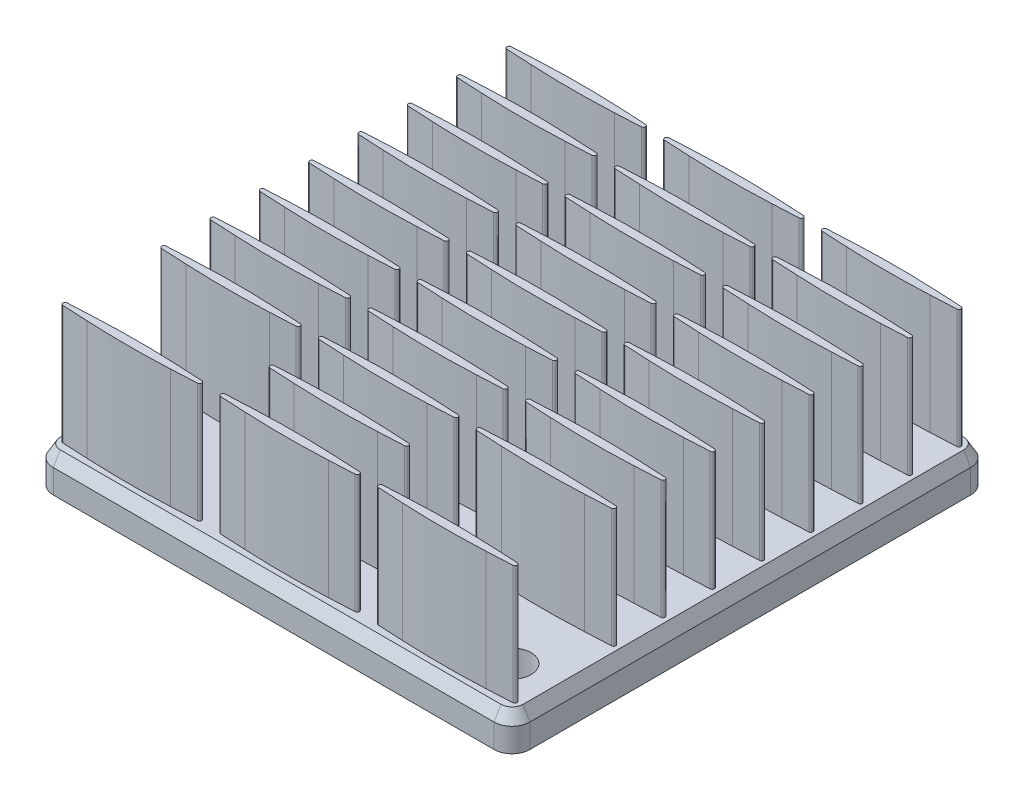
from build123d import *

# Parameters (mm, degrees)
BOSS_EXTRUDE1_DEPTH  = 1
BOSS_EXTRUDE1_TAPER  = -30
BOSS_EXTRUDE2_DEPTH  = 2
BOSS_EXTRUDE3_DEPTH  = 10
BOSS_EXTRUDE4_DEPTH  = 12
BOSS_EXTRUDE5_DEPTH  = 12
BOSS_EXTRUDE6_DEPTH  = 12
BOSS_EXTRUDE7_DEPTH  = 12
BOSS_EXTRUDE8_DEPTH  = 12
BOSS_EXTRUDE9_DEPTH  = 12
BOSS_EXTRUDE10_DEPTH = 12
BOSS_EXTRUDE11_DEPTH = 12
BOSS_EXTRUDE12_DEPTH = 12
BOSS_EXTRUDE13_DEPTH = 12
BOSS_EXTRUDE14_DEPTH = 12
BOSS_EXTRUDE15_DEPTH = 12
BOSS_EXTRUDE16_DEPTH = 12
BOSS_EXTRUDE17_DEPTH = 12
BOSS_EXTRUDE18_DEPTH = 12
BOSS_EXTRUDE19_DEPTH = 12
BOSS_EXTRUDE20_DEPTH = 12
BOSS_EXTRUDE21_DEPTH = 12
BOSS_EXTRUDE22_DEPTH = 12
BOSS_EXTRUDE23_DEPTH = 12
BOSS_EXTRUDE24_DEPTH = 12
BOSS_EXTRUDE25_DEPTH = 12
BOSS_EXTRUDE26_DEPTH = 12
BOSS_EXTRUDE28_DEPTH = 12
BOSS_EXTRUDE30_DEPTH = 12
BOSS_EXTRUDE31_DEPTH = 12
BOSS_EXTRUDE32_DEPTH = 12
SKETCH34_W           = 57.280047681
SKETCH34_H           = 53.627576078
CUT_EXTRUDE1_DEPTH   = 2
SKETCH35_R           = 1.6
CUT_EXTRUDE2_DEPTH   = 10


with BuildPart() as part:
    # Sketch1 → Boss-Extrude1 (new body)
    with BuildSketch(Plane(origin=(0, 3, 0), x_dir=(1, 0, 0), z_dir=(0, 1, 0))):
        with BuildLine():
            Line((-19.422649731, 18.5), (-19.422649731, -18.5))
            ThreePointArc((-19.422649731, -18.5), (-19.152411881, -19.152411881), (-18.5, -19.422649731))
            Line((-18.5, -19.422649731), (18.5, -19.422649731))
            ThreePointArc((18.5, -19.422649731), (19.152411881, -19.152411881), (19.422649731, -18.5))
            Line((19.422649731, -18.5), (19.422649731, 18.5))
            ThreePointArc((19.422649731, 18.5), (19.152411881, 19.152411881), (18.5, 19.422649731))
            Line((18.5, 19.422649731), (-18.5, 19.422649731))
            ThreePointArc((-18.5, 19.422649731), (-19.152411881, 19.152411881), (-19.422649731, 18.5))
        make_face()
    extrude(amount=-BOSS_EXTRUDE1_DEPTH, taper=BOSS_EXTRUDE1_TAPER)

    # Sketch2 → Boss-Extrude2 (add)
    with BuildSketch(Plane.XZ.offset(-2)):
        with BuildLine():
            Line((-20, -18.5), (-20, 18.5))
            ThreePointArc((-20, 18.5), (-19.560660172, 19.560660172), (-18.5, 20))
            Line((-18.5, 20), (18.5, 20))
            ThreePointArc((18.5, 20), (19.560660172, 19.560660172), (20, 18.5))
            Line((20, 18.5), (20, -18.5))
            ThreePointArc((20, -18.5), (19.560660172, -19.560660172), (18.5, -20))
            Line((18.5, -20), (-18.5, -20))
            ThreePointArc((-18.5, -20), (-19.560660172, -19.560660172), (-20, -18.5))
        make_face()
    extrude(amount=BOSS_EXTRUDE2_DEPTH)

    # Sketch3 → Boss-Extrude3 (add)
    with BuildSketch(Plane(origin=(0, 3, 0), x_dir=(-1, 0, 0), z_dir=(0, 1, 0))):
        with BuildLine():
            Line((-16.742786756, -18.917305676), (-18.889007166, -18.8097745))
            ThreePointArc((-18.889007166, -18.8097745), (-19.06, -18.63), (-18.889007166, -18.4502255))
            Line((-18.889007166, -18.4502255), (-16.742786756, -18.342694324))
            ThreePointArc((-16.742786756, -18.342694324), (-13.24, -18.255), (-9.737213244, -18.342694324))
            Line((-9.737213244, -18.342694324), (-7.590992834, -18.4502255))
            ThreePointArc((-7.590992834, -18.4502255), (-7.42, -18.63), (-7.590992834, -18.8097745))
            Line((-7.590992834, -18.8097745), (-9.737213244, -18.917305676))
            ThreePointArc((-9.737213244, -18.917305676), (-13.24, -19.005), (-16.742786756, -18.917305676))
        make_face()
    extrude(amount=BOSS_EXTRUDE3_DEPTH)

    # Sketch4 → Boss-Extrude4 (add)
    with BuildSketch(Plane(origin=(0, 3, 0), x_dir=(-1, 0, 0), z_dir=(0, 1, 0))):
        with BuildLine():
            Line((-3.502786756, -18.917305676), (-5.649007166, -18.8097745))
            ThreePointArc((-5.649007166, -18.8097745), (-5.82, -18.63), (-5.649007166, -18.4502255))
            Line((-5.649007166, -18.4502255), (-3.502786756, -18.342694324))
            ThreePointArc((-3.502786756, -18.342694324), (0, -18.255), (3.502786756, -18.342694324))
            Line((3.502786756, -18.342694324), (5.649007166, -18.4502255))
            ThreePointArc((5.649007166, -18.4502255), (5.82, -18.63), (5.649007166, -18.8097745))
            Line((5.649007166, -18.8097745), (3.502786756, -18.917305676))
            ThreePointArc((3.502786756, -18.917305676), (0, -19.005), (-3.502786756, -18.917305676))
        make_face()
    extrude(amount=BOSS_EXTRUDE4_DEPTH)

    # Sketch5 → Boss-Extrude5 (add)
    with BuildSketch(Plane(origin=(0, 3, 0), x_dir=(-1, 0, 0), z_dir=(0, 1, 0))):
        with BuildLine():
            Line((9.737213244, -18.917305676), (7.590992834, -18.8097745))
            ThreePointArc((7.590992834, -18.8097745), (7.42, -18.63), (7.590992834, -18.4502255))
            Line((7.590992834, -18.4502255), (9.737213244, -18.342694324))
            ThreePointArc((9.737213244, -18.342694324), (13.24, -18.255), (16.742786756, -18.342694324))
            Line((16.742786756, -18.342694324), (18.889007166, -18.4502255))
            ThreePointArc((18.889007166, -18.4502255), (19.06, -18.63), (18.889007166, -18.8097745))
            Line((18.889007166, -18.8097745), (16.742786756, -18.917305676))
            ThreePointArc((16.742786756, -18.917305676), (13.24, -19.005), (9.737213244, -18.917305676))
        make_face()
    extrude(amount=BOSS_EXTRUDE5_DEPTH)

    # Sketch6 → Boss-Extrude6 (add)
    with BuildSketch(Plane(origin=(0, 3, 0), x_dir=(-1, 0, 0), z_dir=(0, 1, 0))):
        with BuildLine():
            Line((-16.742786756, -14.777305676), (-18.889007166, -14.6697745))
            ThreePointArc((-18.889007166, -14.6697745), (-19.06, -14.49), (-18.889007166, -14.3102255))
            Line((-18.889007166, -14.3102255), (-16.742786756, -14.202694324))
            ThreePointArc((-16.742786756, -14.202694324), (-13.24, -14.115), (-9.737213244, -14.202694324))
            Line((-9.737213244, -14.202694324), (-7.590992834, -14.3102255))
            ThreePointArc((-7.590992834, -14.3102255), (-7.42, -14.49), (-7.590992834, -14.6697745))
            Line((-7.590992834, -14.6697745), (-9.737213244, -14.777305676))
            ThreePointArc((-9.737213244, -14.777305676), (-13.24, -14.865), (-16.742786756, -14.777305676))
        make_face()
    extrude(amount=BOSS_EXTRUDE6_DEPTH)

    # Sketch7 → Boss-Extrude7 (add)
    with BuildSketch(Plane(origin=(0, 3, 0), x_dir=(-1, 0, 0), z_dir=(0, 1, 0))):
        with BuildLine():
            Line((-3.502786756, -14.777305676), (-5.649007166, -14.6697745))
            ThreePointArc((-5.649007166, -14.6697745), (-5.82, -14.49), (-5.649007166, -14.3102255))
            Line((-5.649007166, -14.3102255), (-3.502786756, -14.202694324))
            ThreePointArc((-3.502786756, -14.202694324), (0, -14.115), (3.502786756, -14.202694324))
            Line((3.502786756, -14.202694324), (5.649007166, -14.3102255))
            ThreePointArc((5.649007166, -14.3102255), (5.82, -14.49), (5.649007166, -14.6697745))
            Line((5.649007166, -14.6697745), (3.502786756, -14.777305676))
            ThreePointArc((3.502786756, -14.777305676), (0, -14.865), (-3.502786756, -14.777305676))
        make_face()
    extrude(amount=BOSS_EXTRUDE7_DEPTH)

    # Sketch8 → Boss-Extrude8 (add)
    with BuildSketch(Plane(origin=(0, 3, 0), x_dir=(-1, 0, 0), z_dir=(0, 1, 0))):
        with BuildLine():
            Line((9.737213244, -14.777305676), (7.590992834, -14.6697745))
            ThreePointArc((7.590992834, -14.6697745), (7.42, -14.49), (7.590992834, -14.3102255))
            Line((7.590992834, -14.3102255), (9.737213244, -14.202694324))
            ThreePointArc((9.737213244, -14.202694324), (13.24, -14.115), (16.742786756, -14.202694324))
            Line((16.742786756, -14.202694324), (18.889007166, -14.3102255))
            ThreePointArc((18.889007166, -14.3102255), (19.06, -14.49), (18.889007166, -14.6697745))
            Line((18.889007166, -14.6697745), (16.742786756, -14.777305676))
            ThreePointArc((16.742786756, -14.777305676), (13.24, -14.865), (9.737213244, -14.777305676))
        make_face()
    extrude(amount=BOSS_EXTRUDE8_DEPTH)

    # Sketch9 → Boss-Extrude9 (add)
    with BuildSketch(Plane(origin=(0, 3, 0), x_dir=(-1, 0, 0), z_dir=(0, 1, 0))):
        with BuildLine():
            Line((-16.742786756, -10.637305676), (-18.889007166, -10.5297745))
            ThreePointArc((-18.889007166, -10.5297745), (-19.06, -10.35), (-18.889007166, -10.1702255))
            Line((-18.889007166, -10.1702255), (-16.742786756, -10.062694324))
            ThreePointArc((-16.742786756, -10.062694324), (-13.24, -9.975), (-9.737213244, -10.062694324))
            Line((-9.737213244, -10.062694324), (-7.590992834, -10.1702255))
            ThreePointArc((-7.590992834, -10.1702255), (-7.42, -10.35), (-7.590992834, -10.5297745))
            Line((-7.590992834, -10.5297745), (-9.737213244, -10.637305676))
            ThreePointArc((-9.737213244, -10.637305676), (-13.24, -10.725), (-16.742786756, -10.637305676))
        make_face()
    extrude(amount=BOSS_EXTRUDE9_DEPTH)

    # Sketch10 → Boss-Extrude10 (add)
    with BuildSketch(Plane(origin=(0, 3, 0), x_dir=(-1, 0, 0), z_dir=(0, 1, 0))):
        with BuildLine():
            Line((-3.502786756, -10.637305676), (-5.649007166, -10.5297745))
            ThreePointArc((-5.649007166, -10.5297745), (-5.82, -10.35), (-5.649007166, -10.1702255))
            Line((-5.649007166, -10.1702255), (-3.502786756, -10.062694324))
            ThreePointArc((-3.502786756, -10.062694324), (0, -9.975), (3.502786756, -10.062694324))
            Line((3.502786756, -10.062694324), (5.649007166, -10.1702255))
            ThreePointArc((5.649007166, -10.1702255), (5.82, -10.35), (5.649007166, -10.5297745))
            Line((5.649007166, -10.5297745), (3.502786756, -10.637305676))
            ThreePointArc((3.502786756, -10.637305676), (0, -10.725), (-3.502786756, -10.637305676))
        make_face()
    extrude(amount=BOSS_EXTRUDE10_DEPTH)

    # Sketch11 → Boss-Extrude11 (add)
    with BuildSketch(Plane(origin=(0, 3, 0), x_dir=(-1, 0, 0), z_dir=(0, 1, 0))):
        with BuildLine():
            Line((9.737213244, -10.637305676), (7.590992834, -10.5297745))
            ThreePointArc((7.590992834, -10.5297745), (7.42, -10.35), (7.590992834, -10.1702255))
            Line((7.590992834, -10.1702255), (9.737213244, -10.062694324))
            ThreePointArc((9.737213244, -10.062694324), (13.24, -9.975), (16.742786756, -10.062694324))
            Line((16.742786756, -10.062694324), (18.889007166, -10.1702255))
            ThreePointArc((18.889007166, -10.1702255), (19.06, -10.35), (18.889007166, -10.5297745))
            Line((18.889007166, -10.5297745), (16.742786756, -10.637305676))
            ThreePointArc((16.742786756, -10.637305676), (13.24, -10.725), (9.737213244, -10.637305676))
        make_face()
    extrude(amount=BOSS_EXTRUDE11_DEPTH)

    # Sketch12 → Boss-Extrude12 (add)
    with BuildSketch(Plane(origin=(0, 3, 0), x_dir=(-1, 0, 0), z_dir=(0, 1, 0))):
        with BuildLine():
            Line((-16.742786756, -6.497305676), (-18.889007166, -6.3897745))
            ThreePointArc((-18.889007166, -6.3897745), (-19.06, -6.21), (-18.889007166, -6.0302255))
            Line((-18.889007166, -6.0302255), (-16.742786756, -5.922694324))
            ThreePointArc((-16.742786756, -5.922694324), (-13.24, -5.835), (-9.737213244, -5.922694324))
            Line((-9.737213244, -5.922694324), (-7.590992834, -6.0302255))
            ThreePointArc((-7.590992834, -6.0302255), (-7.42, -6.21), (-7.590992834, -6.3897745))
            Line((-7.590992834, -6.3897745), (-9.737213244, -6.497305676))
            ThreePointArc((-9.737213244, -6.497305676), (-13.24, -6.585), (-16.742786756, -6.497305676))
        make_face()
    extrude(amount=BOSS_EXTRUDE12_DEPTH)

    # Sketch13 → Boss-Extrude13 (add)
    with BuildSketch(Plane(origin=(0, 3, 0), x_dir=(-1, 0, 0), z_dir=(0, 1, 0))):
        with BuildLine():
            Line((-3.502786756, -6.497305676), (-5.649007166, -6.3897745))
            ThreePointArc((-5.649007166, -6.3897745), (-5.82, -6.21), (-5.649007166, -6.0302255))
            Line((-5.649007166, -6.0302255), (-3.502786756, -5.922694324))
            ThreePointArc((-3.502786756, -5.922694324), (0, -5.835), (3.502786756, -5.922694324))
            Line((3.502786756, -5.922694324), (5.649007166, -6.0302255))
            ThreePointArc((5.649007166, -6.0302255), (5.82, -6.21), (5.649007166, -6.3897745))
            Line((5.649007166, -6.3897745), (3.502786756, -6.497305676))
            ThreePointArc((3.502786756, -6.497305676), (0, -6.585), (-3.502786756, -6.497305676))
        make_face()
    extrude(amount=BOSS_EXTRUDE13_DEPTH)

    # Sketch14 → Boss-Extrude14 (add)
    with BuildSketch(Plane(origin=(0, 3, 0), x_dir=(-1, 0, 0), z_dir=(0, 1, 0))):
        with BuildLine():
            Line((9.737213244, -6.497305676), (7.590992834, -6.3897745))
            ThreePointArc((7.590992834, -6.3897745), (7.42, -6.21), (7.590992834, -6.0302255))
            Line((7.590992834, -6.0302255), (9.737213244, -5.922694324))
            ThreePointArc((9.737213244, -5.922694324), (13.24, -5.835), (16.742786756, -5.922694324))
            Line((16.742786756, -5.922694324), (18.889007166, -6.0302255))
            ThreePointArc((18.889007166, -6.0302255), (19.06, -6.21), (18.889007166, -6.3897745))
            Line((18.889007166, -6.3897745), (16.742786756, -6.497305676))
            ThreePointArc((16.742786756, -6.497305676), (13.24, -6.585), (9.737213244, -6.497305676))
        make_face()
    extrude(amount=BOSS_EXTRUDE14_DEPTH)

    # Sketch15 → Boss-Extrude15 (add)
    with BuildSketch(Plane(origin=(0, 3, 0), x_dir=(-1, 0, 0), z_dir=(0, 1, 0))):
        with BuildLine():
            Line((-16.742786756, -2.357305676), (-18.889007166, -2.2497745))
            ThreePointArc((-18.889007166, -2.2497745), (-19.06, -2.07), (-18.889007166, -1.8902255))
            Line((-18.889007166, -1.8902255), (-16.742786756, -1.782694324))
            ThreePointArc((-16.742786756, -1.782694324), (-13.24, -1.695), (-9.737213244, -1.782694324))
            Line((-9.737213244, -1.782694324), (-7.590992834, -1.8902255))
            ThreePointArc((-7.590992834, -1.8902255), (-7.42, -2.07), (-7.590992834, -2.2497745))
            Line((-7.590992834, -2.2497745), (-9.737213244, -2.357305676))
            ThreePointArc((-9.737213244, -2.357305676), (-13.24, -2.445), (-16.742786756, -2.357305676))
        make_face()
    extrude(amount=BOSS_EXTRUDE15_DEPTH)

    # Sketch16 → Boss-Extrude16 (add)
    with BuildSketch(Plane(origin=(0, 3, 0), x_dir=(-1, 0, 0), z_dir=(0, 1, 0))):
        with BuildLine():
            Line((-3.502786756, -2.357305676), (-5.649007166, -2.2497745))
            ThreePointArc((-5.649007166, -2.2497745), (-5.82, -2.07), (-5.649007166, -1.8902255))
            Line((-5.649007166, -1.8902255), (-3.502786756, -1.782694324))
            ThreePointArc((-3.502786756, -1.782694324), (0, -1.695), (3.502786756, -1.782694324))
            Line((3.502786756, -1.782694324), (5.649007166, -1.8902255))
            ThreePointArc((5.649007166, -1.8902255), (5.82, -2.07), (5.649007166, -2.2497745))
            Line((5.649007166, -2.2497745), (3.502786756, -2.357305676))
            ThreePointArc((3.502786756, -2.357305676), (0, -2.445), (-3.502786756, -2.357305676))
        make_face()
    extrude(amount=BOSS_EXTRUDE16_DEPTH)

    # Sketch17 → Boss-Extrude17 (add)
    with BuildSketch(Plane(origin=(0, 3, 0), x_dir=(-1, 0, 0), z_dir=(0, 1, 0))):
        with BuildLine():
            Line((9.737213244, -2.357305676), (7.590992834, -2.2497745))
            ThreePointArc((7.590992834, -2.2497745), (7.42, -2.07), (7.590992834, -1.8902255))
            Line((7.590992834, -1.8902255), (9.737213244, -1.782694324))
            ThreePointArc((9.737213244, -1.782694324), (13.24, -1.695), (16.742786756, -1.782694324))
            Line((16.742786756, -1.782694324), (18.889007166, -1.8902255))
            ThreePointArc((18.889007166, -1.8902255), (19.06, -2.07), (18.889007166, -2.2497745))
            Line((18.889007166, -2.2497745), (16.742786756, -2.357305676))
            ThreePointArc((16.742786756, -2.357305676), (13.24, -2.445), (9.737213244, -2.357305676))
        make_face()
    extrude(amount=BOSS_EXTRUDE17_DEPTH)

    # Sketch18 → Boss-Extrude18 (add)
    with BuildSketch(Plane(origin=(0, 3, 0), x_dir=(-1, 0, 0), z_dir=(0, 1, 0))):
        with BuildLine():
            Line((-16.742786756, 1.782694324), (-18.889007166, 1.8902255))
            ThreePointArc((-18.889007166, 1.8902255), (-19.06, 2.07), (-18.889007166, 2.2497745))
            Line((-18.889007166, 2.2497745), (-16.742786756, 2.357305676))
            ThreePointArc((-16.742786756, 2.357305676), (-13.24, 2.445), (-9.737213244, 2.357305676))
            Line((-9.737213244, 2.357305676), (-7.590992834, 2.2497745))
            ThreePointArc((-7.590992834, 2.2497745), (-7.42, 2.07), (-7.590992834, 1.8902255))
            Line((-7.590992834, 1.8902255), (-9.737213244, 1.782694324))
            ThreePointArc((-9.737213244, 1.782694324), (-13.24, 1.695), (-16.742786756, 1.782694324))
        make_face()
    extrude(amount=BOSS_EXTRUDE18_DEPTH)

    # Sketch19 → Boss-Extrude19 (add)
    with BuildSketch(Plane(origin=(0, 3, 0), x_dir=(-1, 0, 0), z_dir=(0, 1, 0))):
        with BuildLine():
            Line((-3.502786756, 1.782694324), (-5.649007166, 1.8902255))
            ThreePointArc((-5.649007166, 1.8902255), (-5.82, 2.07), (-5.649007166, 2.2497745))
            Line((-5.649007166, 2.2497745), (-3.502786756, 2.357305676))
            ThreePointArc((-3.502786756, 2.357305676), (0, 2.445), (3.502786756, 2.357305676))
            Line((3.502786756, 2.357305676), (5.649007166, 2.2497745))
            ThreePointArc((5.649007166, 2.2497745), (5.82, 2.07), (5.649007166, 1.8902255))
            Line((5.649007166, 1.8902255), (3.502786756, 1.782694324))
            ThreePointArc((3.502786756, 1.782694324), (0, 1.695), (-3.502786756, 1.782694324))
        make_face()
    extrude(amount=BOSS_EXTRUDE19_DEPTH)

    # Sketch20 → Boss-Extrude20 (add)
    with BuildSketch(Plane(origin=(0, 3, 0), x_dir=(-1, 0, 0), z_dir=(0, 1, 0))):
        with BuildLine():
            Line((9.737213244, 1.782694324), (7.590992834, 1.8902255))
            ThreePointArc((7.590992834, 1.8902255), (7.42, 2.07), (7.590992834, 2.2497745))
            Line((7.590992834, 2.2497745), (9.737213244, 2.357305676))
            ThreePointArc((9.737213244, 2.357305676), (13.24, 2.445), (16.742786756, 2.357305676))
            Line((16.742786756, 2.357305676), (18.889007166, 2.2497745))
            ThreePointArc((18.889007166, 2.2497745), (19.06, 2.07), (18.889007166, 1.8902255))
            Line((18.889007166, 1.8902255), (16.742786756, 1.782694324))
            ThreePointArc((16.742786756, 1.782694324), (13.24, 1.695), (9.737213244, 1.782694324))
        make_face()
    extrude(amount=BOSS_EXTRUDE20_DEPTH)

    # Sketch21 → Boss-Extrude21 (add)
    with BuildSketch(Plane(origin=(0, 3, 0), x_dir=(-1, 0, 0), z_dir=(0, 1, 0))):
        with BuildLine():
            Line((-16.742786756, 5.922694324), (-18.889007166, 6.0302255))
            ThreePointArc((-18.889007166, 6.0302255), (-19.06, 6.21), (-18.889007166, 6.3897745))
            Line((-18.889007166, 6.3897745), (-16.742786756, 6.497305676))
            ThreePointArc((-16.742786756, 6.497305676), (-13.24, 6.585), (-9.737213244, 6.497305676))
            Line((-9.737213244, 6.497305676), (-7.590992834, 6.3897745))
            ThreePointArc((-7.590992834, 6.3897745), (-7.42, 6.21), (-7.590992834, 6.0302255))
            Line((-7.590992834, 6.0302255), (-9.737213244, 5.922694324))
            ThreePointArc((-9.737213244, 5.922694324), (-13.24, 5.835), (-16.742786756, 5.922694324))
        make_face()
    extrude(amount=BOSS_EXTRUDE21_DEPTH)

    # Sketch22 → Boss-Extrude22 (add)
    with BuildSketch(Plane(origin=(0, 3, 0), x_dir=(-1, 0, 0), z_dir=(0, 1, 0))):
        with BuildLine():
            Line((-3.502786756, 5.922694324), (-5.649007166, 6.0302255))
            ThreePointArc((-5.649007166, 6.0302255), (-5.82, 6.21), (-5.649007166, 6.3897745))
            Line((-5.649007166, 6.3897745), (-3.502786756, 6.497305676))
            ThreePointArc((-3.502786756, 6.497305676), (0, 6.585), (3.502786756, 6.497305676))
            Line((3.502786756, 6.497305676), (5.649007166, 6.3897745))
            ThreePointArc((5.649007166, 6.3897745), (5.82, 6.21), (5.649007166, 6.0302255))
            Line((5.649007166, 6.0302255), (3.502786756, 5.922694324))
            ThreePointArc((3.502786756, 5.922694324), (0, 5.835), (-3.502786756, 5.922694324))
        make_face()
    extrude(amount=BOSS_EXTRUDE22_DEPTH)

    # Sketch23 → Boss-Extrude23 (add)
    with BuildSketch(Plane(origin=(0, 3, 0), x_dir=(-1, 0, 0), z_dir=(0, 1, 0))):
        with BuildLine():
            Line((9.737213244, 5.922694324), (7.590992834, 6.0302255))
            ThreePointArc((7.590992834, 6.0302255), (7.42, 6.21), (7.590992834, 6.3897745))
            Line((7.590992834, 6.3897745), (9.737213244, 6.497305676))
            ThreePointArc((9.737213244, 6.497305676), (13.24, 6.585), (16.742786756, 6.497305676))
            Line((16.742786756, 6.497305676), (18.889007166, 6.3897745))
            ThreePointArc((18.889007166, 6.3897745), (19.06, 6.21), (18.889007166, 6.0302255))
            Line((18.889007166, 6.0302255), (16.742786756, 5.922694324))
            ThreePointArc((16.742786756, 5.922694324), (13.24, 5.835), (9.737213244, 5.922694324))
        make_face()
    extrude(amount=BOSS_EXTRUDE23_DEPTH)

    # Sketch24 → Boss-Extrude24 (add)
    with BuildSketch(Plane(origin=(0, 3, 0), x_dir=(-1, 0, 0), z_dir=(0, 1, 0))):
        with BuildLine():
            Line((-16.742786756, 10.062694324), (-18.889007166, 10.1702255))
            ThreePointArc((-18.889007166, 10.1702255), (-19.06, 10.35), (-18.889007166, 10.5297745))
            Line((-18.889007166, 10.5297745), (-16.742786756, 10.637305676))
            ThreePointArc((-16.742786756, 10.637305676), (-13.24, 10.725), (-9.737213244, 10.637305676))
            Line((-9.737213244, 10.637305676), (-7.590992834, 10.5297745))
            ThreePointArc((-7.590992834, 10.5297745), (-7.42, 10.35), (-7.590992834, 10.1702255))
            Line((-7.590992834, 10.1702255), (-9.737213244, 10.062694324))
            ThreePointArc((-9.737213244, 10.062694324), (-13.24, 9.975), (-16.742786756, 10.062694324))
        make_face()
    extrude(amount=BOSS_EXTRUDE24_DEPTH)

    # Sketch25 → Boss-Extrude25 (add)
    with BuildSketch(Plane(origin=(0, 3, 0), x_dir=(-1, 0, 0), z_dir=(0, 1, 0))):
        with BuildLine():
            Line((-3.502786756, 10.062694324), (-5.649007166, 10.1702255))
            ThreePointArc((-5.649007166, 10.1702255), (-5.82, 10.35), (-5.649007166, 10.5297745))
            Line((-5.649007166, 10.5297745), (-3.502786756, 10.637305676))
            ThreePointArc((-3.502786756, 10.637305676), (0, 10.725), (3.502786756, 10.637305676))
            Line((3.502786756, 10.637305676), (5.649007166, 10.5297745))
            ThreePointArc((5.649007166, 10.5297745), (5.82, 10.35), (5.649007166, 10.1702255))
            Line((5.649007166, 10.1702255), (3.502786756, 10.062694324))
            ThreePointArc((3.502786756, 10.062694324), (0, 9.975), (-3.502786756, 10.062694324))
        make_face()
    extrude(amount=BOSS_EXTRUDE25_DEPTH)

    # Sketch26 → Boss-Extrude26 (add)
    with BuildSketch(Plane(origin=(0, 3, 0), x_dir=(-1, 0, 0), z_dir=(0, 1, 0))):
        with BuildLine():
            Line((9.737213244, 10.062694324), (7.590992834, 10.1702255))
            ThreePointArc((7.590992834, 10.1702255), (7.42, 10.35), (7.590992834, 10.5297745))
            Line((7.590992834, 10.5297745), (9.737213244, 10.637305676))
            ThreePointArc((9.737213244, 10.637305676), (13.24, 10.725), (16.742786756, 10.637305676))
            Line((16.742786756, 10.637305676), (18.889007166, 10.5297745))
            ThreePointArc((18.889007166, 10.5297745), (19.06, 10.35), (18.889007166, 10.1702255))
            Line((18.889007166, 10.1702255), (16.742786756, 10.062694324))
            ThreePointArc((16.742786756, 10.062694324), (13.24, 9.975), (9.737213244, 10.062694324))
        make_face()
    extrude(amount=BOSS_EXTRUDE26_DEPTH)

    # Sketch28 → Boss-Extrude28 (add)
    with BuildSketch(Plane(origin=(0, 3, 0), x_dir=(-1, 0, 0), z_dir=(0, 1, 0))):
        with BuildLine():
            Line((-3.502786756, 14.202694324), (-5.649007166, 14.3102255))
            ThreePointArc((-5.649007166, 14.3102255), (-5.82, 14.49), (-5.649007166, 14.6697745))
            Line((-5.649007166, 14.6697745), (-3.502786756, 14.777305676))
            ThreePointArc((-3.502786756, 14.777305676), (0, 14.865), (3.502786756, 14.777305676))
            Line((3.502786756, 14.777305676), (5.649007166, 14.6697745))
            ThreePointArc((5.649007166, 14.6697745), (5.82, 14.49), (5.649007166, 14.3102255))
            Line((5.649007166, 14.3102255), (3.502786756, 14.202694324))
            ThreePointArc((3.502786756, 14.202694324), (0, 14.115), (-3.502786756, 14.202694324))
        make_face()
    extrude(amount=BOSS_EXTRUDE28_DEPTH)

    # Sketch30 → Boss-Extrude30 (add)
    with BuildSketch(Plane(origin=(0, 3, 0), x_dir=(-1, 0, 0), z_dir=(0, 1, 0))):
        with BuildLine():
            Line((-16.742786756, 18.342694324), (-18.889007166, 18.4502255))
            ThreePointArc((-18.889007166, 18.4502255), (-19.06, 18.63), (-18.889007166, 18.8097745))
            Line((-18.889007166, 18.8097745), (-16.742786756, 18.917305676))
            ThreePointArc((-16.742786756, 18.917305676), (-13.24, 19.005), (-9.737213244, 18.917305676))
            Line((-9.737213244, 18.917305676), (-7.590992834, 18.8097745))
            ThreePointArc((-7.590992834, 18.8097745), (-7.42, 18.63), (-7.590992834, 18.4502255))
            Line((-7.590992834, 18.4502255), (-9.737213244, 18.342694324))
            ThreePointArc((-9.737213244, 18.342694324), (-13.24, 18.255), (-16.742786756, 18.342694324))
        make_face()
    extrude(amount=BOSS_EXTRUDE30_DEPTH)

    # Sketch31 → Boss-Extrude31 (add)
    with BuildSketch(Plane(origin=(0, 3, 0), x_dir=(-1, 0, 0), z_dir=(0, 1, 0))):
        with BuildLine():
            Line((-3.502786756, 18.342694324), (-5.649007166, 18.4502255))
            ThreePointArc((-5.649007166, 18.4502255), (-5.82, 18.63), (-5.649007166, 18.8097745))
            Line((-5.649007166, 18.8097745), (-3.502786756, 18.917305676))
            ThreePointArc((-3.502786756, 18.917305676), (0, 19.005), (3.502786756, 18.917305676))
            Line((3.502786756, 18.917305676), (5.649007166, 18.8097745))
            ThreePointArc((5.649007166, 18.8097745), (5.82, 18.63), (5.649007166, 18.4502255))
            Line((5.649007166, 18.4502255), (3.502786756, 18.342694324))
            ThreePointArc((3.502786756, 18.342694324), (0, 18.255), (-3.502786756, 18.342694324))
        make_face()
    extrude(amount=BOSS_EXTRUDE31_DEPTH)

    # Sketch32 → Boss-Extrude32 (add)
    with BuildSketch(Plane(origin=(0, 3, 0), x_dir=(-1, 0, 0), z_dir=(0, 1, 0))):
        with BuildLine():
            Line((9.737213244, 18.342694324), (7.590992834, 18.4502255))
            ThreePointArc((7.590992834, 18.4502255), (7.42, 18.63), (7.590992834, 18.8097745))
            Line((7.590992834, 18.8097745), (9.737213244, 18.917305676))
            ThreePointArc((9.737213244, 18.917305676), (13.24, 19.005), (16.742786756, 18.917305676))
            Line((16.742786756, 18.917305676), (18.889007166, 18.8097745))
            ThreePointArc((18.889007166, 18.8097745), (19.06, 18.63), (18.889007166, 18.4502255))
            Line((18.889007166, 18.4502255), (16.742786756, 18.342694324))
            ThreePointArc((16.742786756, 18.342694324), (13.24, 18.255), (9.737213244, 18.342694324))
        make_face()
    extrude(amount=BOSS_EXTRUDE32_DEPTH)

    # Sketch34 → Cut-Extrude1 (cut)
    with BuildSketch(Plane(origin=(0, 15, 0), x_dir=(1, 0, 0), z_dir=(0, 1, 0))):
        with Locations((3.611774962, -2.08819609)):
            Rectangle(SKETCH34_W, SKETCH34_H)
    extrude(amount=-CUT_EXTRUDE1_DEPTH, mode=Mode.SUBTRACT)

    # Sketch35 → Cut-Extrude2 (cut)
    with BuildSketch(Plane.XZ):
        with Locations((16, 16)):
            Circle(SKETCH35_R)
        with Locations((-16, 16)):
            Circle(SKETCH35_R)
    extrude(amount=-CUT_EXTRUDE2_DEPTH, mode=Mode.SUBTRACT)


solid = part.part
